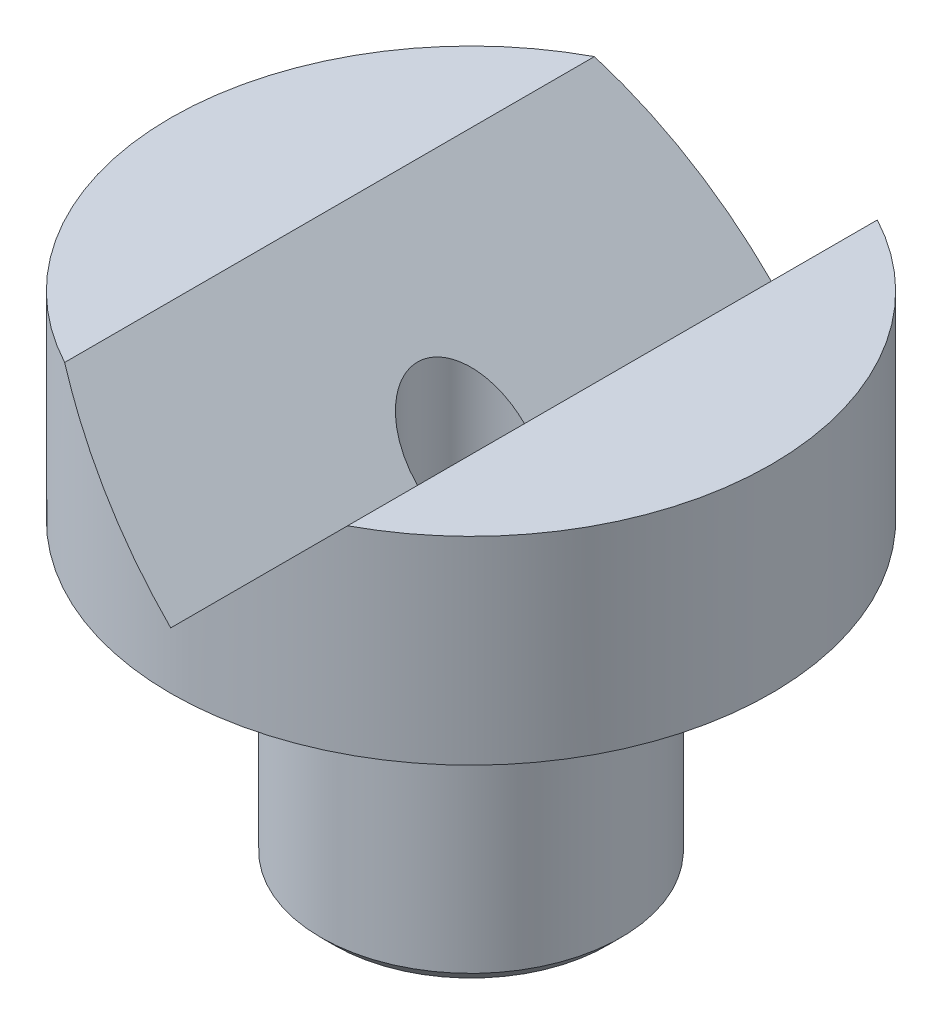
from build123d import *

# Parameters (mm, degrees)
CUT_EXTRUDE1_DEPTH      = 7.35
CUT_EXTRUDE1_DEPTH_BACK = 7.35
SKETCH7_W               = 1.1303
SKETCH7_H               = 10.541
CHAMFER1_SIZE           = 0.2921


with BuildPart() as part:
    # Sketch9 → Revolve1 (revolve)
    with BuildSketch(Plane.XY, mode=Mode.PRIVATE) as revolve1_sk:
        Polygon((0, 4.191), (6.35, 4.191), (6.35, 0), (3.175, 0), (3.175, -6.35), (0, -6.35), align=None)
    revolve(revolve1_sk.sketch.rotate(Axis((0, 6.439023264, 0), (0, -1, 0)), 90), axis=Axis((0, 6.439023264, 0), (0, -1, 0)))  # turned: the seam where the file's is

    # Sketch3 → Cut-Extrude1 (cut, two sides)
    with BuildSketch(Plane.XY) as cut_extrude1_sk:
        Polygon((-2.991528061, 4.191), (2.991528061, 4.191), (0, 1.199471939), align=None)
    extrude(amount=CUT_EXTRUDE1_DEPTH, mode=Mode.SUBTRACT)
    extrude(cut_extrude1_sk.sketch, amount=-CUT_EXTRUDE1_DEPTH_BACK, mode=Mode.SUBTRACT)

    # Sketch7 → Cut-Revolve1 (revolve, cut)
    with BuildSketch(Plane.XY, mode=Mode.PRIVATE) as cut_revolve1_sk:
        with Locations((0.56515, -1.0795)):
            Rectangle(SKETCH7_W, SKETCH7_H)
    revolve(cut_revolve1_sk.sketch.rotate(Axis((0, 13.979393491, 0), (0, -1, 0)), 90), axis=Axis((0, 13.979393491, 0), (0, -1, 0)), mode=Mode.SUBTRACT)  # turned: the seam where the file's is

    # Chamfer1
    chamfer1_edges = [part.edges().sort_by_distance(p)[0] for p in [
        (0, -6.35, -1.1303),
        (0, -6.35, -3.175),
    ]]
    chamfer(chamfer1_edges, length=CHAMFER1_SIZE)

    # Sketch10 → Cut-Revolve2 (revolve, cut)
    with BuildSketch(Plane.XY, mode=Mode.PRIVATE) as cut_revolve2_sk:
        with BuildLine():
            Line((3.175, -0.735852294), (3.910852294, 0))
            ThreePointArc((3.910852294, 0), (3.175, 0), (3.175, -0.735852294))
        make_face()
    revolve(cut_revolve2_sk.sketch.rotate(Axis((0, 0, 0), (0, 1, 0)), 270), axis=Axis((0, 0, 0), (0, 1, 0)), mode=Mode.SUBTRACT)  # turned: the seam where the file's is


solid = part.part
